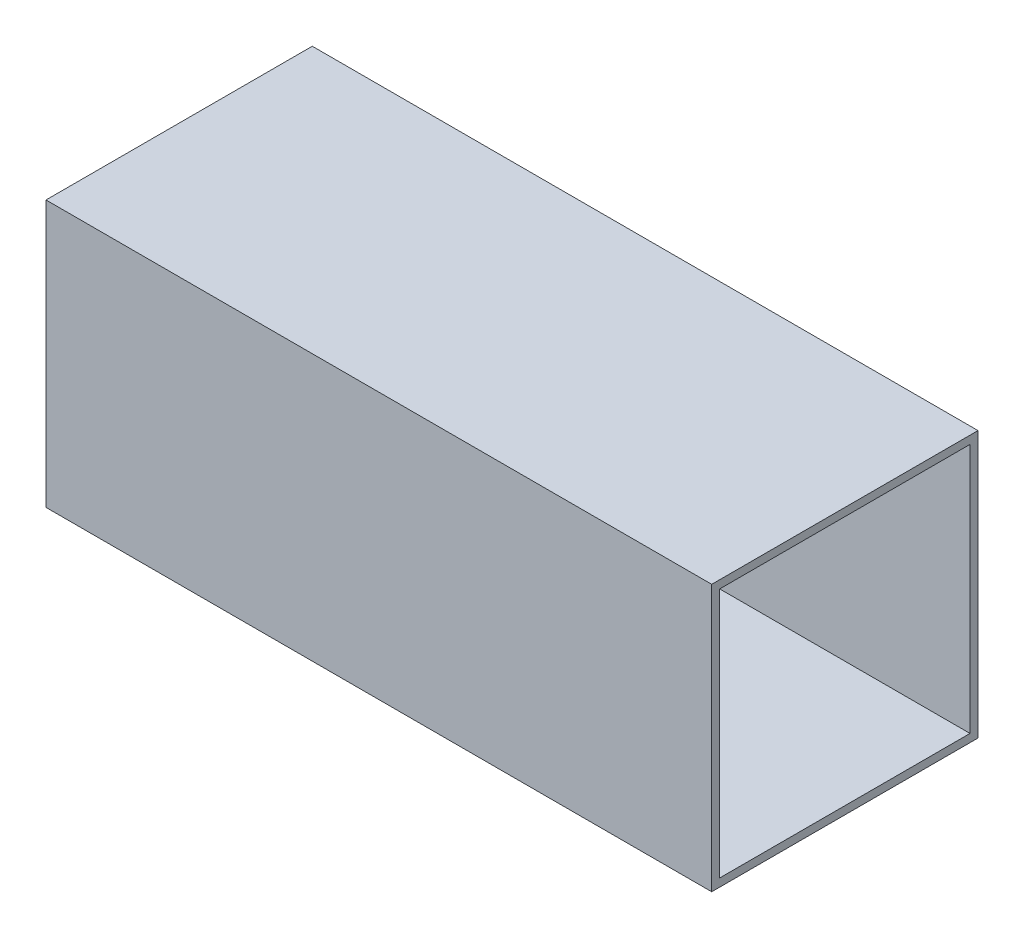
from build123d import *

# Parameters (mm, degrees)
CROQUIS1_W              = 250
CROQUIS1_H              = 100
SALIENTE_EXTRUIR1_DEPTH = 100
VACIADO1_T              = -3
SALIENTE_EXTRUIR2_REACH = 99


with BuildPart() as part:
    # Croquis1 → Saliente-Extruir1 (new body)
    with BuildSketch(Plane.XY):
        with Locations((125, 50)):
            Rectangle(CROQUIS1_W, CROQUIS1_H)
    extrude(amount=SALIENTE_EXTRUIR1_DEPTH)

    # Vaciado1
    vaciado1_openings = [part.faces().sort_by_distance(p)[0] for p in [
        (250, 50, 50),
        (0, 50, 50),
    ]]
    offset(amount=VACIADO1_T, openings=vaciado1_openings, kind=Kind.INTERSECTION)

    # Croquis2 → Saliente-Extruir2 (add, up to next)
    with BuildSketch(Plane.XY.offset(3), mode=Mode.PRIVATE) as saliente_extruir2_sk1:
        with BuildLine():
            Line((35, 38.990872976), (111.166875619, 65.349857161))
            ThreePointArc((111.166875619, 65.349857161), (145.157572396, 67.664766629), (175.650108959, 52.46833655))
            ThreePointArc((175.650108959, 52.46833655), (178.345677223, 41.442147101), (169, 35))
            Line((169, 35), (49, 35))
            Line((49, 35), (35, 38.990872976))
        make_face()
    saliente_extruir2_tool1 = extrude(saliente_extruir2_sk1.sketch, amount=SALIENTE_EXTRUIR2_REACH, mode=Mode.PRIVATE) - part.part
    add(saliente_extruir2_tool1.solids().sort_by_distance((118.929072, 48.395279, 3))[0])


solid = part.part
